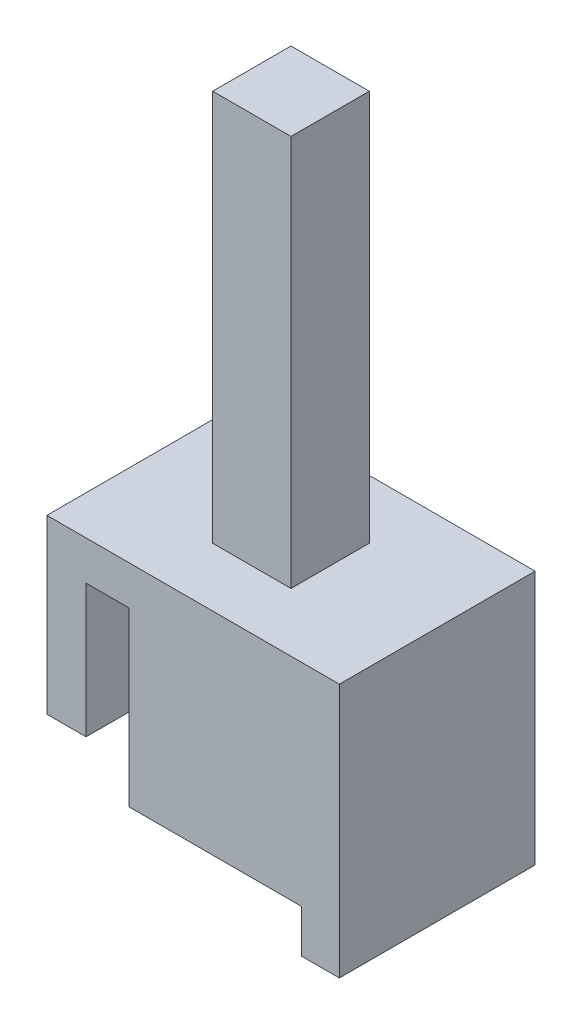
from build123d import *

# Parameters (mm, degrees)
BOSS_EXTRUDE2_DEPTH = 12.7
SKETCH2_W           = 5.08
SKETCH2_H           = 5.08
BOSS_EXTRUDE3_DEPTH = 25.4


with BuildPart() as part:
    # Sketch1 → Boss-Extrude2 (new body)
    with BuildSketch(Plane.XY):
        Polygon((0, 11.176), (0, 0), (11.176, 0), (11.176, -2.794), (13.641294118, -2.794), (13.641294118, 13.716), (-5.334, 13.716), (-5.334, 2.54), (-2.794, 2.54), (-2.794, 11.176), align=None)
    extrude(amount=BOSS_EXTRUDE2_DEPTH)

    # Sketch2 → Boss-Extrude3 (add)
    with BuildSketch(Plane(origin=(0, 13.716, 0), x_dir=(1, 0, 0), z_dir=(0, 1, 0))):
        with Locations((4.153647059, -6.35)):
            Rectangle(SKETCH2_W, SKETCH2_H)
    extrude(amount=BOSS_EXTRUDE3_DEPTH)


solid = part.part
